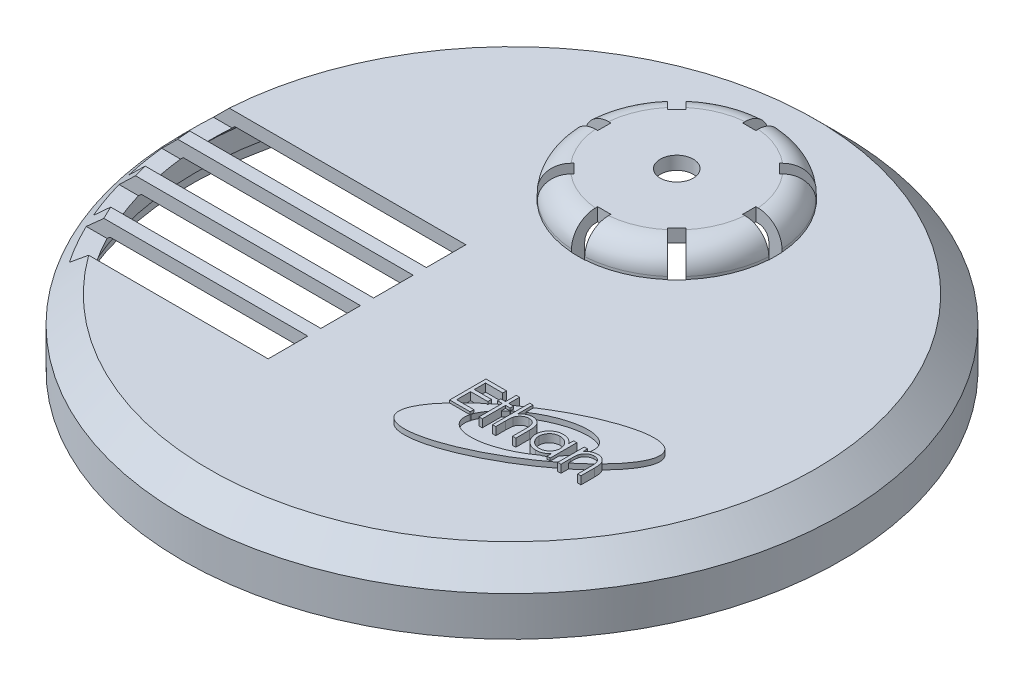
from build123d import *

# Parameters (mm, degrees)
SKETCH2_R           = 31.75
BOSS_EXTRUDE1_DEPTH = 6.35
CHAMFER1_SIZE       = 2.54
SKETCH3_R           = 9.525
BOSS_EXTRUDE2_DEPTH = 2.54
FILLET1_R           = 2.286
SHELL1_T            = -1.27
SKETCH4_R           = 30.988
CUT_EXTRUDE1_DEPTH  = 1.27
SKETCH5_R           = 1.5875
CUT_EXTRUDE2_DEPTH  = 46.772886079
SKETCH6_W           = 2.54
SKETCH6_H           = 1.27
CUT_EXTRUDE3_DEPTH  = 46.772886079
CIRPATTERN1_COUNT   = 8
SKETCH7_W           = 25.4
SKETCH7_H           = 3.81
CUT_EXTRUDE4_DEPTH  = 1.524
LPATTERN1_COUNT     = 4
LPATTERN1_PITCH     = 5.08
BOSS_EXTRUDE3_DEPTH = 0.762
SKETCH9_RX          = 9.444145301
SKETCH9_RY          = 3.015325863
SKETCH9_RX_2        = 4.938076641
SKETCH9_RY_2        = 2.355603646
BOSS_EXTRUDE4_DEPTH = 0.508


with BuildPart() as part:
    # Sketch2 → Boss-Extrude1 (new body)
    with BuildSketch(Plane(origin=(0, 0, 0), x_dir=(1, 0, 0), z_dir=(0, 1, 0))):
        with Locations(Location((0, 0, 0), (0, 0, 270))):
            Circle(SKETCH2_R)
    extrude(amount=BOSS_EXTRUDE1_DEPTH)

    # Chamfer1
    chamfer1_edges = [part.edges().sort_by_distance(p)[0] for p in [
        (0, 6.35, -31.75),
    ]]
    chamfer(chamfer1_edges, length=CHAMFER1_SIZE)

    # Sketch3 → Boss-Extrude2 (add)
    with BuildSketch(Plane(origin=(0, 6.35, 0), x_dir=(1, 0, 0), z_dir=(0, 1, 0))):
        with Locations(Location((0, 15.875, 0), (0, 0, 270))):
            Circle(SKETCH3_R)
    extrude(amount=BOSS_EXTRUDE2_DEPTH)

    # Fillet1
    fillet1_edges = [part.edges().sort_by_distance(p)[0] for p in [
        (0, 8.89, -25.4),
    ]]
    fillet(fillet1_edges, radius=FILLET1_R)

    # Shell1
    shell1_openings = [part.faces().sort_by_distance(p)[0] for p in [
        (0, 0, 0),
    ]]
    offset(amount=SHELL1_T, openings=shell1_openings, kind=Kind.INTERSECTION)

    # Sketch4 → Cut-Extrude1 (cut)
    with BuildSketch(Plane.XZ):
        with Locations(Location((0, 0, 0), (0, 0, 270))):
            Circle(SKETCH4_R)
    extrude(amount=-CUT_EXTRUDE1_DEPTH, mode=Mode.SUBTRACT)

    # Sketch5 → Cut-Extrude2 (cut, through all)
    with BuildSketch(Plane(origin=(0, 8.89, 0), x_dir=(1, 0, 0), z_dir=(0, 1, 0))):
        with Locations(Location((0, 15.875, 0), (0, 0, 270))):
            Circle(SKETCH5_R)
    extrude(amount=-CUT_EXTRUDE2_DEPTH, mode=Mode.SUBTRACT)

    # Sketch6 → Cut-Extrude3 (cut, through all)
    with BuildSketch(Plane(origin=(0, 8.89, 0), x_dir=(1, 0, 0), z_dir=(0, 1, 0))):
        with Locations((8.255, 15.875)):
            Rectangle(SKETCH6_W, SKETCH6_H)
    cut_extrude3 = extrude(amount=-CUT_EXTRUDE3_DEPTH, mode=Mode.SUBTRACT)

    # CirPattern1: Cut-Extrude3 ×8 about axis
    cirpattern1_axis = Axis((0, 0, -15.875), (0, 1, 0))
    for i in range(1, CIRPATTERN1_COUNT):
        add(cut_extrude3.rotate(cirpattern1_axis, i * 360 / CIRPATTERN1_COUNT), mode=Mode.SUBTRACT)

    # Sketch7 → Cut-Extrude4 (cut)
    with BuildSketch(Plane(origin=(0, 6.35, 0), x_dir=(1, 0, 0), z_dir=(0, 1, 0))):
        with Locations((-19.05, 0)):
            Rectangle(SKETCH7_W, SKETCH7_H)
    cut_extrude4 = extrude(amount=-CUT_EXTRUDE4_DEPTH, mode=Mode.SUBTRACT)

    # LPattern1: Cut-Extrude4 ×4
    with Locations(*[(0, 0, i * LPATTERN1_PITCH) for i in range(1, LPATTERN1_COUNT)]):
        add(cut_extrude4, mode=Mode.SUBTRACT)

    # Sketch8 → Boss-Extrude3 (add)
    with BuildSketch(Plane(origin=(0, 6.35, 0), x_dir=(1, 0, 0), z_dir=(0, 1, 0))):
        Polygon((6.584328456, -9.091086966), (8.558687431, -9.091086966), (8.558687431, -9.450061325), (6.89843102, -9.450061325), (6.89843102, -10.526984401), (8.558687431, -10.526984401), (8.558687431, -10.88595876), (6.89843102, -10.88595876), (6.89843102, -12.232112607), (8.558687431, -12.232112607), (8.558687431, -12.591086966), (6.584328456, -12.591086966), align=None)
        Polygon((9.411251533, -9.001343376), (9.725354097, -9.001343376), (9.725354097, -10.033394658), (10.174072046, -10.033394658), (10.174072046, -10.347497222), (9.725354097, -10.347497222), (9.725354097, -12.591086966), (9.411251533, -12.591086966), (9.411251533, -10.347497222), (8.962533584, -10.347497222), (8.962533584, -10.033394658), (9.411251533, -10.033394658), align=None)
        with BuildLine():
            Line((10.712533584, -9.001343376), (11.026636148, -9.001343376))
            Line((11.026636148, -9.001343376), (11.026636148, -10.516467575))
            add(Edge.make_bspline(
                [(11.026636148, -10.516467575), (11.06035345, -10.474323592), (11.126002764, -10.3922671), (11.236498881, -10.285205909), (11.349969753, -10.192407288), (11.470334563, -10.11853683), (11.595385083, -10.060180287), (11.725648728, -10.018792641), (11.861149699, -9.993341544), (11.953174849, -9.990143126), (11.9997932, -9.988522863)],
                knots=[0, 0, 0, 0, 1.125788106, 2.19196713, 3.20547328, 4.180437432, 5.132270164, 6.079753143, 7.027236121, 8, 8, 8, 8], degree=3))
            add(Edge.make_bspline(
                [(11.9997932, -9.988522863), (12.047123593, -9.990268293), (12.139760588, -9.993684521), (12.274642051, -10.020697902), (12.400602926, -10.06685534), (12.517268768, -10.130022365), (12.622093466, -10.208695193), (12.71494323, -10.299526715), (12.790784029, -10.404800634), (12.842383146, -10.502056887), (12.875956553, -10.588595641), (12.89720838, -10.662832154), (12.915227578, -10.745554067), (12.930927314, -10.836718799), (12.941390895, -10.936763971), (12.949795513, -11.045238225), (12.955771968, -11.162135343), (12.956003572, -11.243055593), (12.956123328, -11.284897062)],
                knots=[0, 0, 0, 0, 1.235656852, 2.418478516, 3.575258207, 4.727955599, 5.870717718, 6.98870536, 8.107142894, 9.245821548, 9.854588956, 10.528768408, 11.260415777, 12.065282286, 12.943670737, 13.886611085, 14.907229059, 16, 16, 16, 16], degree=3))
            Line((12.956123328, -11.284897062), (12.956123328, -12.591086966))
            Line((12.956123328, -12.591086966), (12.642020764, -12.591086966))
            Line((12.642020764, -12.591086966), (12.642020764, -11.387961966))
            add(Edge.make_bspline(
                [(12.642020764, -11.387961966), (12.641830461, -11.353139296), (12.641466443, -11.286529456), (12.640263099, -11.191163347), (12.637576883, -11.104667213), (12.633236057, -11.027318261), (12.62867075, -10.959008658), (12.622387433, -10.899837603), (12.615077199, -10.849723828), (12.608508417, -10.819559199), (12.605562431, -10.806030876)],
                knots=[0, 0, 0, 0, 1.430932559, 2.737130458, 3.918967929, 4.986496826, 5.920444988, 6.731744033, 7.431208747, 8, 8, 8, 8], degree=3))
            add(Edge.make_bspline(
                [(12.605562431, -10.806030876), (12.594138185, -10.766336612), (12.572175141, -10.690024621), (12.521127164, -10.586362211), (12.457368153, -10.497977471), (12.379520891, -10.426063183), (12.288962527, -10.369651643), (12.185102563, -10.330583861), (12.068918494, -10.306336139), (11.987067023, -10.303896836), (11.944404578, -10.302625427)],
                knots=[0, 0, 0, 0, 1.090059168, 2.095632401, 3.037101401, 3.955032261, 4.878929692, 5.839099886, 6.873700383, 8, 8, 8, 8], degree=3))
            add(Edge.make_bspline(
                [(11.944404578, -10.302625427), (11.919136805, -10.303101253), (11.869132535, -10.304042901), (11.794983869, -10.3134968), (11.723054805, -10.328945519), (11.652652627, -10.349850057), (11.58526943, -10.378295594), (11.518941105, -10.411225783), (11.455546896, -10.451534038), (11.393961079, -10.496759805), (11.336643546, -10.546829565), (11.28331643, -10.59967652), (11.23577809, -10.655951484), (11.192709499, -10.714751601), (11.155531213, -10.776883394), (11.123078131, -10.841747712), (11.095542435, -10.909429858), (11.081859743, -10.95640492), (11.075013552, -10.979909081)],
                knots=[0, 0, 0, 0, 1.024319606, 2.027102035, 3.025350316, 4.005802111, 5.00026367, 5.987881639, 7.005602596, 8.042517216, 9.083927026, 10.089214625, 11.084353441, 12.06828073, 13.041928858, 14.016821737, 15.00770877, 16, 16, 16, 16], degree=3))
            add(Edge.make_bspline(
                [(11.075013552, -10.979909081), (11.071074125, -10.996930032), (11.062489628, -11.034020779), (11.053174795, -11.095195103), (11.044836998, -11.166281475), (11.037788449, -11.247172075), (11.033465362, -11.338163317), (11.028807121, -11.438634276), (11.027073107, -11.549214297), (11.026786155, -11.626109805), (11.026636148, -11.666307318)],
                knots=[0, 0, 0, 0, 0.607992626, 1.324890765, 2.152360218, 3.099583803, 4.150613268, 5.323148443, 6.60066238, 8, 8, 8, 8], degree=3))
            Line((11.026636148, -11.666307318), (11.026636148, -12.591086966))
            Line((11.026636148, -12.591086966), (10.712533584, -12.591086966))
            Line((10.712533584, -12.591086966), (10.712533584, -9.001343376))
        make_face()
        with BuildLine():
            Line((16.276636148, -10.033394658), (16.276636148, -12.591086966))
            Line((16.276636148, -12.591086966), (15.962533584, -12.591086966))
            Line((15.962533584, -12.591086966), (15.962533584, -12.148679113))
            add(Edge.make_bspline(
                [(15.962533584, -12.148679113), (15.927114794, -12.188718707), (15.857994578, -12.266856478), (15.742553461, -12.368938651), (15.620185283, -12.453316972), (15.491483961, -12.521466888), (15.356565718, -12.572658944), (15.215729631, -12.609045103), (15.06891825, -12.632438938), (14.968665895, -12.63477496), (14.91786211, -12.63595876)],
                knots=[0, 0, 0, 0, 1.074387032, 2.096679803, 3.090159297, 4.057316773, 5.018401886, 5.985159533, 6.978961417, 8, 8, 8, 8], degree=3))
            add(Edge.make_bspline(
                [(14.91786211, -12.63595876), (14.872694156, -12.634732388), (14.783620951, -12.632313928), (14.652591874, -12.613551624), (14.526499625, -12.583421002), (14.405225052, -12.541520113), (14.289552907, -12.485939291), (14.17849281, -12.419398043), (14.072620118, -12.340157213), (13.973548579, -12.249569185), (13.882316579, -12.151174198), (13.802255306, -12.046228651), (13.735502226, -11.935186347), (13.679682145, -11.819453193), (13.636685801, -11.698138274), (13.606712167, -11.571661106), (13.58797172, -11.440171232), (13.585554259, -11.350631709), (13.584328456, -11.305229594)],
                knots=[0, 0, 0, 0, 1.033919861, 2.038935746, 3.024066025, 3.998881131, 4.97069526, 5.957263378, 6.95902576, 7.993208707, 9.027059324, 10.027763471, 11.009749337, 11.988697705, 12.965288445, 13.950418724, 14.960734635, 16, 16, 16, 16], degree=3))
            add(Edge.make_bspline(
                [(13.584328456, -11.305229594), (13.585581428, -11.26076589), (13.588058484, -11.172863547), (13.606511704, -11.043584849), (13.637542713, -10.919066588), (13.681090561, -10.799709645), (13.736932516, -10.685369595), (13.804860603, -10.57596557), (13.884879727, -10.471196172), (13.977132134, -10.373524946), (14.077066904, -10.283304331), (14.183975635, -10.204895286), (14.295198917, -10.137178437), (14.412461927, -10.083524961), (14.534029032, -10.040115856), (14.660982478, -10.010082888), (14.792794056, -9.992385567), (14.882284548, -9.989822803), (14.927677815, -9.988522863)],
                knots=[0, 0, 0, 0, 1.020392517, 2.01726096, 2.990465484, 3.961182959, 4.928053699, 5.906110375, 6.912531644, 7.948652711, 8.985773172, 9.998621852, 10.987621588, 11.969261332, 12.953316658, 13.946091881, 14.958173133, 16, 16, 16, 16], degree=3))
            add(Edge.make_bspline(
                [(14.927677815, -9.988522863), (14.979877674, -9.989960615), (15.082239134, -9.992779977), (15.231967143, -10.016242705), (15.373611621, -10.055881172), (15.508265973, -10.10979867), (15.63544666, -10.181447399), (15.753949644, -10.27182736), (15.865015127, -10.380368547), (15.929395419, -10.463738992), (15.962533584, -10.506651869)],
                knots=[0, 0, 0, 0, 1.038897134, 2.037228247, 3.008116434, 3.962042015, 4.918381754, 5.904844433, 6.921570401, 8, 8, 8, 8], degree=3))
            Line((15.962533584, -10.506651869), (15.962533584, -10.033394658))
            Line((15.962533584, -10.033394658), (16.276636148, -10.033394658))
        make_face()
        with BuildLine():
            add(Edge.make_bspline(
                [(14.931884546, -10.302625427), (14.885970208, -10.304259065), (14.795342608, -10.307483606), (14.662298606, -10.332657101), (14.534985192, -10.374541695), (14.414039118, -10.431823597), (14.301370901, -10.503852333), (14.20067723, -10.590973717), (14.111134529, -10.690810731), (14.035826265, -10.802912841), (13.974435768, -10.923090932), (13.931268736, -11.04871537), (13.902799488, -11.177520348), (13.899890968, -11.264883034), (13.89843102, -11.308735203)],
                knots=[0, 0, 0, 0, 1.031046209, 2.035121221, 3.029706178, 4.034933723, 5.034054252, 6.02443088, 7.017295772, 8.038157696, 9.050218397, 10.03989886, 11.016116709, 12, 12, 12, 12], degree=3))
            add(Edge.make_bspline(
                [(13.89843102, -11.308735203), (13.900295914, -11.35232531), (13.90401839, -11.439334666), (13.930769085, -11.568315243), (13.975648958, -11.693969285), (14.036891021, -11.815230278), (14.113577646, -11.927814379), (14.202466298, -12.029554501), (14.30441658, -12.117044089), (14.417344087, -12.190281663), (14.537952057, -12.249444184), (14.664785989, -12.290609823), (14.795461627, -12.317187604), (14.884313961, -12.320292081), (14.929080059, -12.321856196)],
                knots=[0, 0, 0, 0, 0.979072187, 1.954306742, 2.945804271, 3.96968567, 4.997920485, 5.998718438, 6.996577872, 8.005894225, 9.015743152, 10.005417472, 10.995077863, 12, 12, 12, 12], degree=3))
            add(Edge.make_bspline(
                [(14.929080059, -12.321856196), (14.974526562, -12.320196232), (15.064915148, -12.316894729), (15.198353856, -12.291613464), (15.327848819, -12.249844665), (15.451636047, -12.191945538), (15.566952178, -12.120188183), (15.670450056, -12.036181091), (15.757966024, -11.938477907), (15.832158634, -11.831101454), (15.890334051, -11.713389458), (15.93271011, -11.588055267), (15.957764015, -11.455094519), (15.960921745, -11.364230592), (15.962533584, -11.317849786)],
                knots=[0, 0, 0, 0, 1.01762866, 2.023962475, 3.030623092, 4.058876274, 5.077231937, 6.066672613, 7.034107872, 8.005628644, 8.981990164, 9.965428785, 10.961468474, 12, 12, 12, 12], degree=3))
            add(Edge.make_bspline(
                [(15.962533584, -11.317849786), (15.961573928, -11.282511956), (15.959685021, -11.212955922), (15.945254451, -11.110828405), (15.922299525, -11.013094679), (15.889953355, -10.91965199), (15.84746207, -10.831016974), (15.796214304, -10.746553214), (15.735308855, -10.666700003), (15.665726158, -10.592556932), (15.589560956, -10.524930469), (15.508966415, -10.464566229), (15.422987668, -10.414977456), (15.333070631, -10.373936184), (15.239059297, -10.341277034), (15.140188677, -10.319489341), (15.03750969, -10.30452902), (14.967463635, -10.303266639), (14.931884546, -10.302625427)],
                knots=[0, 0, 0, 0, 1.050140795, 2.067009409, 3.05949893, 4.030605086, 5.00011959, 5.97591094, 6.962425594, 7.979863591, 8.993523472, 9.986985069, 10.967611495, 11.937549037, 12.921786183, 13.919465291, 14.943216303, 16, 16, 16, 16], degree=3))
        make_face(mode=Mode.SUBTRACT)
        with BuildLine():
            Line((16.994584866, -10.033394658), (17.308687431, -10.033394658))
            Line((17.308687431, -10.033394658), (17.308687431, -10.494732799))
            add(Edge.make_bspline(
                [(17.308687431, -10.494732799), (17.342225066, -10.452890076), (17.407306017, -10.371692813), (17.51569035, -10.264972238), (17.63023425, -10.177027013), (17.750236254, -10.106923219), (17.875859264, -10.054076593), (18.006337534, -10.015910662), (18.14245224, -9.993025833), (18.235016677, -9.990035603), (18.281844482, -9.988522863)],
                knots=[0, 0, 0, 0, 1.12780773, 2.188550248, 3.19190651, 4.159438251, 5.104880172, 6.052711206, 7.014878035, 8, 8, 8, 8], degree=3))
            add(Edge.make_bspline(
                [(18.281844482, -9.988522863), (18.329175116, -9.990268058), (18.421812584, -9.993683827), (18.556690645, -10.020700518), (18.682664039, -10.066845773), (18.799283595, -10.130057844), (18.904410808, -10.208664317), (18.996735659, -10.300242099), (19.073098907, -10.405578182), (19.12429627, -10.503301338), (19.158021917, -10.589990132), (19.179254255, -10.664236883), (19.197285236, -10.746955034), (19.212916984, -10.837894623), (19.223494096, -10.937692813), (19.231836388, -11.045940505), (19.237815082, -11.162602636), (19.238052289, -11.243289263), (19.23817461, -11.284897062)],
                knots=[0, 0, 0, 0, 1.235846778, 2.418850247, 3.575807741, 4.728682307, 5.871620074, 6.994088408, 8.11269785, 9.256955736, 9.865816715, 10.540099792, 11.271859618, 12.076849838, 12.949306005, 13.892391288, 14.913166135, 16, 16, 16, 16], degree=3))
            Line((19.23817461, -11.284897062), (19.23817461, -12.591086966))
            Line((19.23817461, -12.591086966), (18.924072046, -12.591086966))
            Line((18.924072046, -12.591086966), (18.924072046, -11.387961966))
            add(Edge.make_bspline(
                [(18.924072046, -11.387961966), (18.923878838, -11.353139521), (18.923509264, -11.28653011), (18.922343617, -11.191161087), (18.919533811, -11.104674508), (18.915585498, -11.027277141), (18.909806467, -10.959043304), (18.903783836, -10.899834028), (18.896418859, -10.849724485), (18.889855946, -10.819559403), (18.886912591, -10.806030876)],
                knots=[0, 0, 0, 0, 1.430800155, 2.736877192, 3.918605307, 4.986035426, 5.920637409, 6.731861385, 7.431261377, 8, 8, 8, 8], degree=3))
            add(Edge.make_bspline(
                [(18.886912591, -10.806030876), (18.876287059, -10.766319691), (18.855836199, -10.689887946), (18.805302215, -10.586213594), (18.741488035, -10.498015406), (18.663590185, -10.425838684), (18.57236111, -10.369667847), (18.468053967, -10.330693893), (18.351675326, -10.306317624), (18.269820944, -10.303890492), (18.227156982, -10.302625427)],
                knots=[0, 0, 0, 0, 1.084156227, 2.086665306, 3.027808233, 3.945421172, 4.874247719, 5.839848303, 6.874090471, 8, 8, 8, 8], degree=3))
            add(Edge.make_bspline(
                [(18.227156982, -10.302625427), (18.201889298, -10.303101432), (18.151885205, -10.304043433), (18.077735233, -10.313494731), (18.00581106, -10.328953186), (17.935390851, -10.349821824), (17.867883057, -10.378484093), (17.801118766, -10.411013463), (17.737612002, -10.451561675), (17.676008605, -10.496752297), (17.618695797, -10.546831504), (17.565367459, -10.599676014), (17.517829439, -10.655951618), (17.474760763, -10.714751565), (17.4375825, -10.776883403), (17.405129412, -10.84174771), (17.377593717, -10.909429859), (17.363911025, -10.95640492), (17.357064834, -10.979909081)],
                knots=[0, 0, 0, 0, 1.023777757, 2.026029729, 3.023749952, 4.003683103, 4.997618607, 5.993177895, 7.010360494, 8.046726602, 9.087585522, 10.09234134, 11.086953743, 12.070360549, 13.043493632, 14.017870808, 15.008233677, 16, 16, 16, 16], degree=3))
            add(Edge.make_bspline(
                [(17.357064834, -10.979909081), (17.353125186, -10.997164284), (17.344548777, -11.034727958), (17.335285597, -11.096372378), (17.326878022, -11.167682353), (17.319841063, -11.24857467), (17.315535647, -11.339332545), (17.31084125, -11.439568383), (17.309132189, -11.549681871), (17.308839835, -11.626343564), (17.308687431, -11.666307318)],
                knots=[0, 0, 0, 0, 0.615963638, 1.340920617, 2.168419149, 3.115676021, 4.16674242, 5.331190069, 6.6087489, 8, 8, 8, 8], degree=3))
            Line((17.308687431, -11.666307318), (17.308687431, -12.591086966))
            Line((17.308687431, -12.591086966), (16.994584866, -12.591086966))
            Line((16.994584866, -12.591086966), (16.994584866, -10.033394658))
        make_face()
    extrude(amount=BOSS_EXTRUDE3_DEPTH)

    # Sketch9 → Boss-Extrude4 (add)
    with BuildSketch(Plane(origin=(0, 6.35, 0), x_dir=(1, 0, 0), z_dir=(0, 1, 0))):
        with Locations(Location((12.956123328, -11.284897062), (0, 0, 32.193326473))):
            Ellipse(SKETCH9_RX, SKETCH9_RY)
        with Locations(Location((12.956123328, -11.284897062), (0, 0, 28.436709495))):
            Ellipse(SKETCH9_RX_2, SKETCH9_RY_2, mode=Mode.SUBTRACT)
    extrude(amount=BOSS_EXTRUDE4_DEPTH)


solid = part.part
